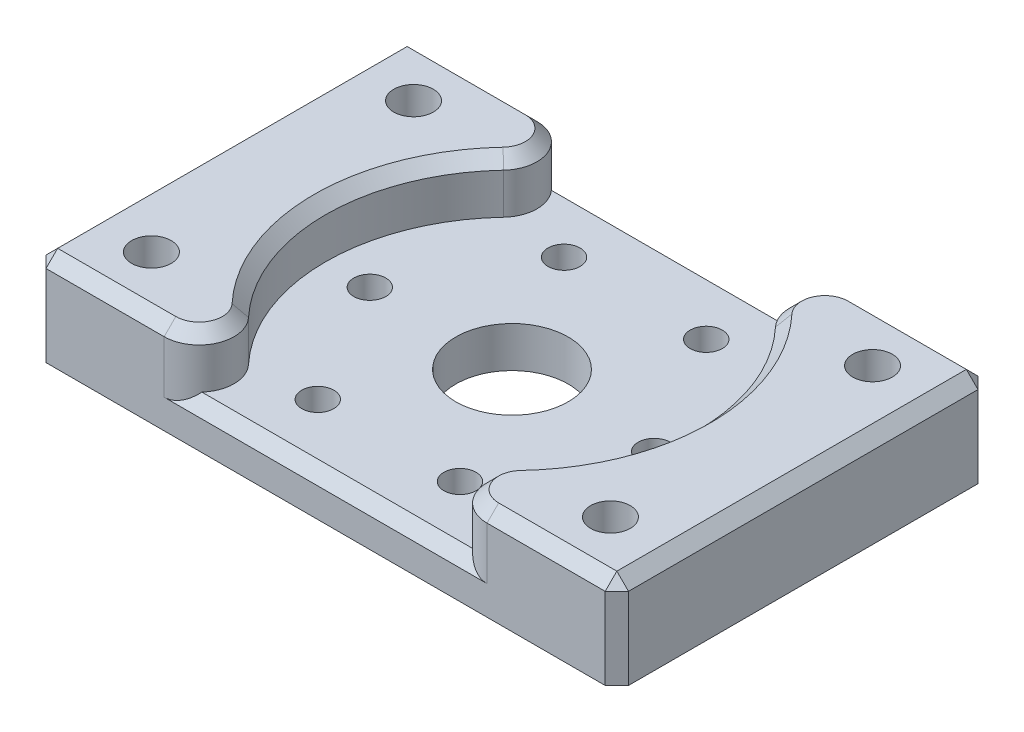
from build123d import *

# Parameters (mm, degrees)
SKETCH2_W           = 63.5
SKETCH2_H           = 40.64
SKETCH2_R           = 2.159
SKETCH2_R_2         = 1.75
SKETCH2_R_3         = 6.125
BOSS_EXTRUDE2_DEPTH = 10.16
SKETCH2_4_R         = 2.159
CUT_EXTRUDE1_DEPTH  = 6.985
CUT_EXTRUDE2_START  = -5.715
SKETCH3_R           = 1.75
SKETCH3_R_2         = 6.125
CUT_EXTRUDE2_DEPTH  = 5.715
CHAMFER1_SIZE       = 1.27


with BuildPart() as part:
    # Sketch2 → Boss-Extrude2 (new body)
    with BuildSketch(Plane(origin=(0, 0, 0), x_dir=(1, 0, 0), z_dir=(0, 1, 0))):
        Rectangle(SKETCH2_W, SKETCH2_H)
        with Locations((-25.019, 14.2875)):
            Circle(SKETCH2_R, mode=Mode.SUBTRACT)
        with Locations((7.75, 13.423393759)):
            Circle(SKETCH2_R_2, mode=Mode.SUBTRACT)
        with Locations((-7.75, 13.423393759)):
            Circle(SKETCH2_R_2, mode=Mode.SUBTRACT)
        with Locations((-15.5, 0)):
            Circle(SKETCH2_R_2, mode=Mode.SUBTRACT)
        with Locations((-7.75, -13.423393759)):
            Circle(SKETCH2_R_2, mode=Mode.SUBTRACT)
        with Locations((7.75, -13.423393759)):
            Circle(SKETCH2_R_2, mode=Mode.SUBTRACT)
        with Locations((15.5, 0)):
            Circle(SKETCH2_R_2, mode=Mode.SUBTRACT)
        with Locations((-25.019, -14.2875)):
            Circle(SKETCH2_R, mode=Mode.SUBTRACT)
        with Locations((25.019, -14.2875)):
            Circle(SKETCH2_R, mode=Mode.SUBTRACT)
        Circle(SKETCH2_R_3, mode=Mode.SUBTRACT)
        with Locations((25.019, 14.2875)):
            Circle(SKETCH2_R, mode=Mode.SUBTRACT)
    extrude(amount=BOSS_EXTRUDE2_DEPTH)

    # Sketch2_4 → Cut-Extrude1 (cut)
    # profile 1 of 4: a face of its own
    with BuildSketch(Plane(origin=(0, 0, 0), x_dir=(1, 0, 0), z_dir=(0, 1, 0))):
        Polygon((-28.34005, 12.370090889), (-25.019, 10.452681777), (-21.69795, 12.370090889), (-21.69795, 16.204909111), (-25.019, 18.122318223), (-28.34005, 16.204909111), align=None)
        with Locations((-25.019, 14.2875)):
            Circle(SKETCH2_4_R, mode=Mode.SUBTRACT)
    # profile 2 of 4: a face of its own
    with BuildSketch(Plane(origin=(0, 0, 0), x_dir=(1, 0, 0), z_dir=(0, 1, 0))):
        Polygon((25.019, 10.452681777), (28.34005, 12.370090889), (28.34005, 16.204909111), (25.019, 18.122318223), (21.69795, 16.204909111), (21.69795, 12.370090889), align=None)
        with Locations((25.019, 14.2875)):
            Circle(SKETCH2_4_R, mode=Mode.SUBTRACT)
    # profile 3 of 4: a face of its own
    with BuildSketch(Plane(origin=(0, 0, 0), x_dir=(1, 0, 0), z_dir=(0, 1, 0))):
        Polygon((25.019, -18.122318223), (28.34005, -16.204909111), (28.34005, -12.370090889), (25.019, -10.452681777), (21.69795, -12.370090889), (21.69795, -16.204909111), align=None)
        with Locations((25.019, -14.2875)):
            Circle(SKETCH2_4_R, mode=Mode.SUBTRACT)
    # profile 4 of 4: a face of its own
    with BuildSketch(Plane(origin=(0, 0, 0), x_dir=(1, 0, 0), z_dir=(0, 1, 0))):
        Polygon((-25.019, -10.452681777), (-28.34005, -12.370090889), (-28.34005, -16.204909111), (-25.019, -18.122318223), (-21.69795, -16.204909111), (-21.69795, -12.370090889), align=None)
        with Locations((-25.019, -14.2875)):
            Circle(SKETCH2_4_R, mode=Mode.SUBTRACT)
    extrude(amount=CUT_EXTRUDE1_DEPTH, mode=Mode.SUBTRACT)

    # Sketch3 → Cut-Extrude2 (cut)
    with BuildSketch(Plane(origin=(0, 10.16, 0), x_dir=(1, 0, 0), z_dir=(0, 1, 0)).offset(CUT_EXTRUDE2_START)):
        with BuildLine():
            ThreePointArc((14.819062067, 13.903157895), (14.101340421, 18.023940484), (17.597636205, 20.32))
            Line((17.597636205, 20.32), (17.597636205, 38.276075745))
            Line((17.597636205, 38.276075745), (-18.310773436, 40.893260665))
            Line((-18.310773436, 40.893260665), (-17.597636205, 20.32))
            ThreePointArc((-17.597636205, 20.32), (-14.101340421, 18.023940484), (-14.819062067, 13.903157895))
            ThreePointArc((-14.819062067, 13.903157895), (-20.32, 0), (-14.819062067, -13.903157895))
            ThreePointArc((-14.819062067, -13.903157895), (-14.101340421, -18.023940484), (-17.597636205, -20.32))
            Line((-17.597636205, -20.32), (-25.350098393, -30.312218712))
            Line((-25.350098393, -30.312218712), (-13.787636205, -33.380642411))
            Line((-13.787636205, -33.380642411), (4.251165531, -33.380642411))
            Line((4.251165531, -33.380642411), (18.013202248, -32.308644201))
            Line((18.013202248, -32.308644201), (17.597636205, -20.32))
            ThreePointArc((17.597636205, -20.32), (14.101340421, -18.023940484), (14.819062067, -13.903157895))
            ThreePointArc((14.819062067, -13.903157895), (20.32, 0), (14.819062067, 13.903157895))
        make_face()
        with Locations((-15.5, 0)):
            Circle(SKETCH3_R, mode=Mode.SUBTRACT)
        with Locations((-7.75, -13.423393759)):
            Circle(SKETCH3_R, mode=Mode.SUBTRACT)
        with Locations((7.75, -13.423393759)):
            Circle(SKETCH3_R, mode=Mode.SUBTRACT)
        Circle(SKETCH3_R_2, mode=Mode.SUBTRACT)
        with Locations((15.5, 0)):
            Circle(SKETCH3_R, mode=Mode.SUBTRACT)
        with Locations((-7.75, 13.423393759)):
            Circle(SKETCH3_R, mode=Mode.SUBTRACT)
        with Locations((7.75, 13.423393759)):
            Circle(SKETCH3_R, mode=Mode.SUBTRACT)
    extrude(amount=CUT_EXTRUDE2_DEPTH, mode=Mode.SUBTRACT)

    # Chamfer1
    chamfer1_edges = [part.edges().sort_by_distance(p)[0] for p in [
        (0, 4.445, -20.32),
        (0, 4.445, 20.32),
        (-24.673818102, 10.16, 20.32),
        (-14.101340421, 10.16, 18.023940484),
        (-20.32, 10.16, 0),
        (-14.101340421, 10.16, -18.023940484),
        (-24.673818102, 10.16, -20.32),
        (-31.75, 5.08, 20.32),
        (-31.75, 10.16, 0),
        (-31.75, 5.08, -20.32),
        (24.673818102, 10.16, 20.32),
        (14.101340421, 10.16, 18.023940484),
        (20.32, 10.16, 0),
        (14.101340421, 10.16, -18.023940484),
        (24.673818102, 10.16, -20.32),
        (31.75, 5.08, -20.32),
        (31.75, 10.16, 0),
        (31.75, 5.08, 20.32),
    ]]
    chamfer(chamfer1_edges, length=CHAMFER1_SIZE)


solid = part.part
